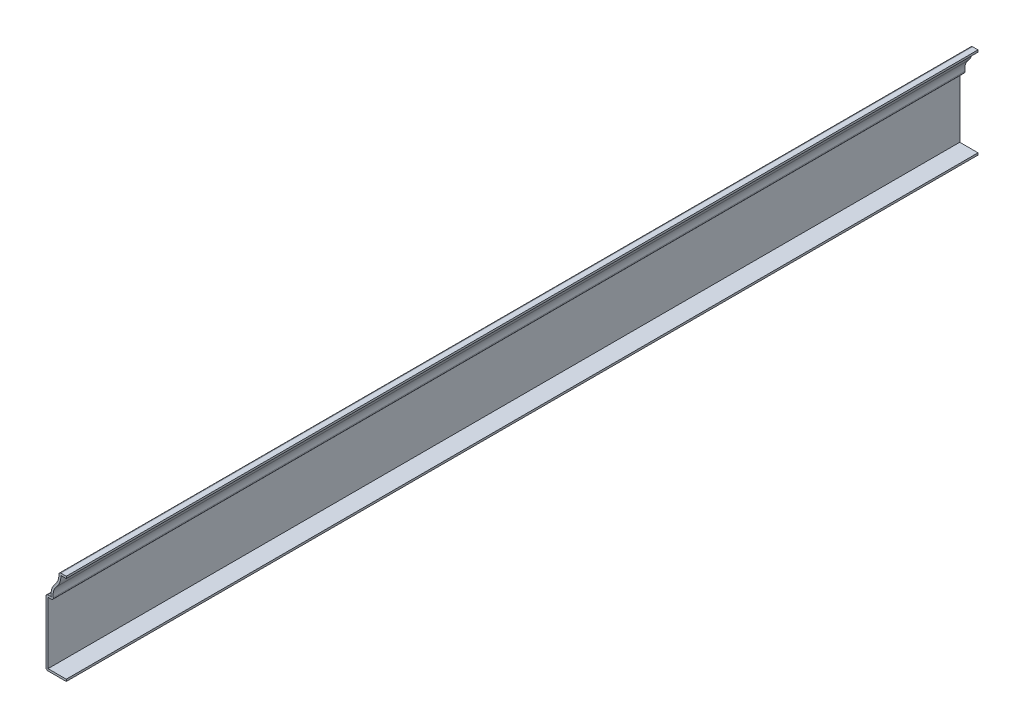
from build123d import *

# Parameters (mm, degrees)
EXTRUDE_THIN1_DEPTH = 571.5
FILLET1_R           = 1.27


with BuildPart() as part:
    # Sketch1 → Extrude-Thin1 (new body)
    with BuildSketch(Plane.XY):
        with BuildLine():
            Line((0, 0), (-12.7, 0))
            Line((-12.7, 0), (-12.7, 41.275))
            Line((-12.7, 41.275), (-9.395603078, 41.275))
            ThreePointArc((-9.395603078, 41.275), (-9.143551703, 45.508230695), (-7.079051539, 49.2125))
            ThreePointArc((-7.079051539, 49.2125), (-5.014551375, 52.916769305), (-4.7625, 57.15))
            Line((-4.7625, 57.15), (0, 57.15))
            Line((0, 57.15), (0, 55.88))
            Line((0, 55.88), (-3.367126275, 55.88))
            ThreePointArc((-3.367126275, 55.88), (-4.028057277, 51.855131977), (-6.135178, 48.362792554))
            ThreePointArc((-6.135178, 48.362792554), (-8.104553119, 44.408529309), (-7.75303386, 40.005))
            Line((-7.75303386, 40.005), (-11.43, 40.005))
            Line((-11.43, 40.005), (-11.43, 1.27))
            Line((-11.43, 1.27), (0, 1.27))
            Line((0, 1.27), (0, 0))
        make_face()
    extrude(amount=-EXTRUDE_THIN1_DEPTH)

    # Fillet1
    fillet1_edges = [part.edges().sort_by_distance(p)[0] for p in [
        (-7.75303386, 40.005, -285.75),
        (-12.7, 0, -285.75),
        (-12.7, 41.275, -285.75),
        (-4.7625, 57.15, -285.75),
    ]]
    fillet(fillet1_edges, radius=FILLET1_R)


solid = part.part
